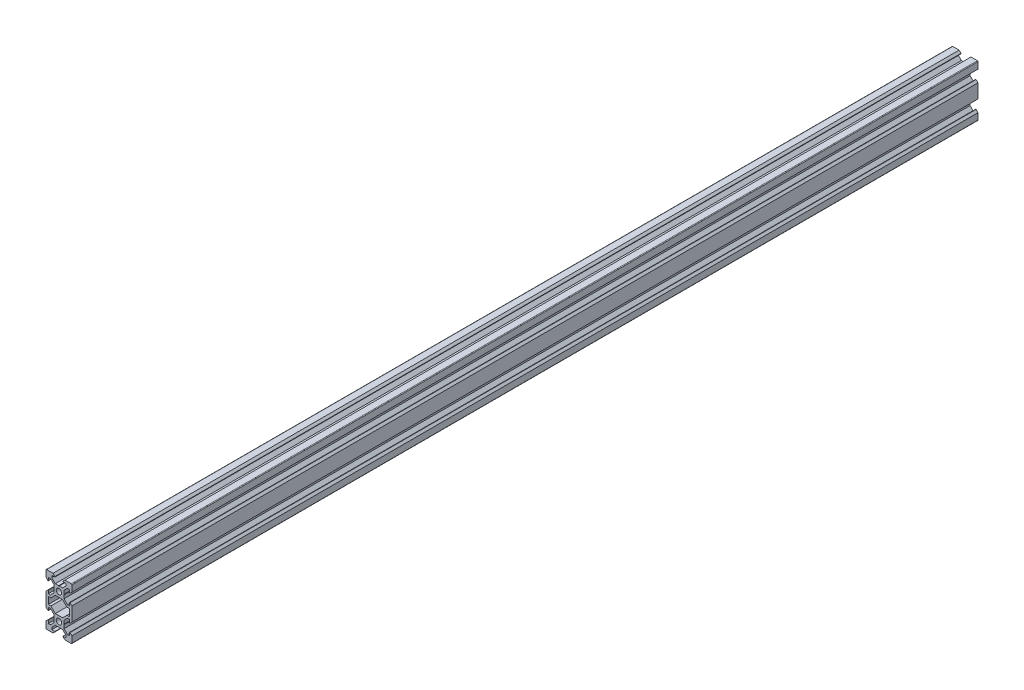
from build123d import *

# Parameters (mm, degrees)
SKETCH1_R           = 2.1
BOSS_EXTRUDE1_DEPTH = 700


with BuildPart() as part:
    # Sketch1 → Boss-Extrude1 (new body)
    with BuildSketch(Plane.XY):
        with BuildLine():
            Line((4.58, -20), (9.5, -20))
            ThreePointArc((9.5, -20), (9.853553391, -19.853553391), (10, -19.5))
            Line((10, -19.5), (10, -14.58))
            Line((10, -14.58), (8.545, -13.125))
            Line((8.545, -13.125), (8.2, -13.125))
            Line((8.2, -13.125), (8.2, -15.5))
            Line((8.2, -15.5), (6.560660172, -15.5))
            Line((6.560660172, -15.5), (3.9, -12.839339828))
            Line((3.9, -12.839339828), (3.9, -10.21))
            Line((3.9, -10.21), (3.69, -10))
            Line((3.69, -10), (3.9, -9.79))
            Line((3.9, -9.79), (3.9, -7.160660172))
            Line((3.9, -7.160660172), (6.560660172, -4.5))
            Line((6.560660172, -4.5), (8.2, -4.5))
            Line((8.2, -4.5), (8.2, -6.875))
            Line((8.2, -6.875), (8.545, -6.875))
            Line((8.545, -6.875), (10, -5.42))
            Line((10, -5.42), (10, 5.42))
            Line((10, 5.42), (8.545, 6.875))
            Line((8.545, 6.875), (8.2, 6.875))
            Line((8.2, 6.875), (8.2, 4.5))
            Line((8.2, 4.5), (6.560660172, 4.5))
            Line((6.560660172, 4.5), (3.9, 7.160660172))
            Line((3.9, 7.160660172), (3.9, 9.79))
            Line((3.9, 9.79), (3.69, 10))
            Line((3.69, 10), (3.9, 10.21))
            Line((3.9, 10.21), (3.9, 12.839339828))
            Line((3.9, 12.839339828), (6.560660172, 15.5))
            Line((6.560660172, 15.5), (8.2, 15.5))
            Line((8.2, 15.5), (8.2, 13.125))
            Line((8.2, 13.125), (8.545, 13.125))
            Line((8.545, 13.125), (10, 14.58))
            Line((10, 14.58), (10, 19.5))
            ThreePointArc((10, 19.5), (9.853553391, 19.853553391), (9.5, 20))
            Line((9.5, 20), (4.58, 20))
            Line((4.58, 20), (3.125, 18.545))
            Line((3.125, 18.545), (3.125, 18.2))
            Line((3.125, 18.2), (5.5, 18.2))
            Line((5.5, 18.2), (5.5, 16.560660172))
            Line((5.5, 16.560660172), (2.839339828, 13.9))
            Line((2.839339828, 13.9), (0.21, 13.9))
            Line((0.21, 13.9), (0, 13.69))
            Line((0, 13.69), (-0.21, 13.9))
            Line((-0.21, 13.9), (-2.839339828, 13.9))
            Line((-2.839339828, 13.9), (-5.5, 16.560660172))
            Line((-5.5, 16.560660172), (-5.5, 18.2))
            Line((-5.5, 18.2), (-3.125, 18.2))
            Line((-3.125, 18.2), (-3.125, 18.545))
            Line((-3.125, 18.545), (-4.58, 20))
            Line((-4.58, 20), (-9.5, 20))
            ThreePointArc((-9.5, 20), (-9.853553391, 19.853553391), (-10, 19.5))
            Line((-10, 19.5), (-10, 14.58))
            Line((-10, 14.58), (-8.545, 13.125))
            Line((-8.545, 13.125), (-8.2, 13.125))
            Line((-8.2, 13.125), (-8.2, 15.5))
            Line((-8.2, 15.5), (-6.560660172, 15.5))
            Line((-6.560660172, 15.5), (-3.9, 12.839339828))
            Line((-3.9, 12.839339828), (-3.9, 10.21))
            Line((-3.9, 10.21), (-3.69, 10))
            Line((-3.69, 10), (-3.9, 9.79))
            Line((-3.9, 9.79), (-3.9, 7.160660172))
            Line((-3.9, 7.160660172), (-6.560660172, 4.5))
            Line((-6.560660172, 4.5), (-8.2, 4.5))
            Line((-8.2, 4.5), (-8.2, 6.875))
            Line((-8.2, 6.875), (-8.545, 6.875))
            Line((-8.545, 6.875), (-10, 5.42))
            Line((-10, 5.42), (-10, -5.42))
            Line((-10, -5.42), (-8.545, -6.875))
            Line((-8.545, -6.875), (-8.2, -6.875))
            Line((-8.2, -6.875), (-8.2, -4.5))
            Line((-8.2, -4.5), (-6.560660172, -4.5))
            Line((-6.560660172, -4.5), (-3.9, -7.160660172))
            Line((-3.9, -7.160660172), (-3.9, -9.79))
            Line((-3.9, -9.79), (-3.69, -10))
            Line((-3.69, -10), (-3.9, -10.21))
            Line((-3.9, -10.21), (-3.9, -12.839339828))
            Line((-3.9, -12.839339828), (-6.560660172, -15.5))
            Line((-6.560660172, -15.5), (-8.2, -15.5))
            Line((-8.2, -15.5), (-8.2, -13.125))
            Line((-8.2, -13.125), (-8.545, -13.125))
            Line((-8.545, -13.125), (-10, -14.58))
            Line((-10, -14.58), (-10, -19.5))
            ThreePointArc((-10, -19.5), (-9.853553391, -19.853553391), (-9.5, -20))
            Line((-9.5, -20), (-4.58, -20))
            Line((-4.58, -20), (-3.125, -18.545))
            Line((-3.125, -18.545), (-3.125, -18.2))
            Line((-3.125, -18.2), (-5.5, -18.2))
            Line((-5.5, -18.2), (-5.5, -16.560660172))
            Line((-5.5, -16.560660172), (-2.839339828, -13.9))
            Line((-2.839339828, -13.9), (-0.21, -13.9))
            Line((-0.21, -13.9), (0, -13.69))
            Line((0, -13.69), (0.21, -13.9))
            Line((0.21, -13.9), (2.839339828, -13.9))
            Line((2.839339828, -13.9), (5.5, -16.560660172))
            Line((5.5, -16.560660172), (5.5, -18.2))
            Line((5.5, -18.2), (3.125, -18.2))
            Line((3.125, -18.2), (3.125, -18.545))
            Line((3.125, -18.545), (4.58, -20))
        make_face()
        with Locations((0, -10)):
            Circle(SKETCH1_R, mode=Mode.SUBTRACT)
        Polygon((-6.239339828, -2.7), (-8.2, -2.7), (-8.2, 2.7), (-6.239339828, 2.7), (-2.839339828, 6.1), (2.839339828, 6.1), (6.239339828, 2.7), (8.2, 2.7), (8.2, -2.7), (6.239339828, -2.7), (2.839339828, -6.1), (-2.839339828, -6.1), align=None, mode=Mode.SUBTRACT)
        with Locations((0, 10)):
            Circle(SKETCH1_R, mode=Mode.SUBTRACT)
    extrude(amount=BOSS_EXTRUDE1_DEPTH)


solid = part.part
